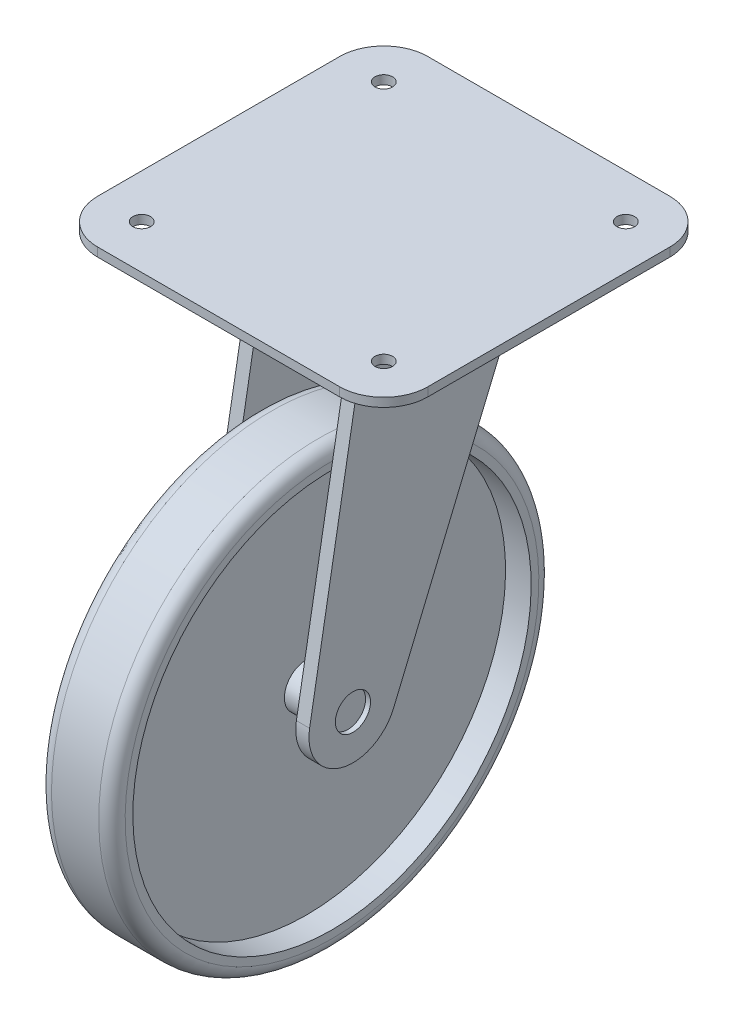
from build123d import *

# Parameters (mm, degrees)
SKETCH1_W           = 75
SKETCH1_H           = 75
SKETCH1_R           = 2
BOSS_EXTRUDE1_DEPTH = 2
FILLET1_R           = 10
SKETCH2_R           = 25
SKETCH2_R_2         = 21.258264894
BOSS_EXTRUDE2_DEPTH = 6
BOSS_EXTRUDE3_START = 10
SKETCH3_R           = 4
BOSS_EXTRUDE3_DEPTH = 3


with BuildPart() as part:
    # Sketch1 → Boss-Extrude1 (new body)
    with BuildSketch(Plane(origin=(0, 0, 0), x_dir=(1, 0, 0), z_dir=(0, 1, 0))):
        Rectangle(SKETCH1_W, SKETCH1_H)
        with Locations((27.5, 27.5)):
            Circle(SKETCH1_R, mode=Mode.SUBTRACT)
        with Locations((27.5, -27.5)):
            Circle(SKETCH1_R, mode=Mode.SUBTRACT)
        with Locations((-27.5, -27.5)):
            Circle(SKETCH1_R, mode=Mode.SUBTRACT)
        with Locations((-27.5, 27.5)):
            Circle(SKETCH1_R, mode=Mode.SUBTRACT)
    extrude(amount=-BOSS_EXTRUDE1_DEPTH)

    # Fillet1
    fillet1_edges = [part.edges().sort_by_distance(p)[0] for p in [
        (-37.5, -1, -37.5),
        (37.5, -1, -37.5),
        (37.5, -1, 37.5),
        (-37.5, -1, 37.5),
    ]]
    fillet(fillet1_edges, radius=FILLET1_R)

    # Sketch2 → Boss-Extrude2 (add)
    with BuildSketch(Plane.XZ.offset(2)):
        Circle(SKETCH2_R)
        Circle(SKETCH2_R_2, mode=Mode.SUBTRACT)
    extrude(amount=BOSS_EXTRUDE2_DEPTH)

    # Sketch3 → Boss-Extrude3 (add)
    with BuildSketch(Plane(origin=(0, 0, 0), x_dir=(0, 0, -1), z_dir=(1, 0, 0)).offset(BOSS_EXTRUDE3_START)):
        with BuildLine():
            Line((-17.549509853, -8), (20.96355147, -8))
            Line((20.96355147, -8), (-10.774863226, -83.859643959))
            ThreePointArc((-10.774863226, -83.859643959), (-22.809331855, -89.597273286), (-29.850246108, -78.275862069))
            Line((-29.850246108, -78.275862069), (-17.549509853, -8))
        make_face()
        with Locations((-20, -80)):
            Circle(SKETCH3_R, mode=Mode.SUBTRACT)
    boss_extrude3 = extrude(amount=BOSS_EXTRUDE3_DEPTH)

    # Mirror1: Boss-Extrude3 across plane
    add(boss_extrude3.mirror(Plane(origin=(0, 0, 0), x_dir=(0, 0, 1), z_dir=(1, 0, 0))))


with BuildPart() as body_2:
    # Sketch4 → Revolve1 (revolve)
    with BuildSketch(Plane.XY.offset(20)):
        with BuildLine():
            Line((2.427228953, -34.748253365), (8.240625297, -34.748253365))
            Line((8.240625297, -34.748253365), (8.240625297, -33))
            ThreePointArc((8.240625297, -33), (7.361945641, -30.878679656), (5.240625297, -30))
            Line((5.240625297, -30), (-5.497712052, -30))
            ThreePointArc((-5.497712052, -30), (-7.619032396, -30.878679656), (-8.497712052, -33))
            Line((-8.497712052, -33), (-8.497712052, -34.748253365))
            Line((-8.497712052, -34.748253365), (-2.649289123, -34.748253365))
            Line((-2.649289123, -34.748253365), (-2.649289123, -75))
            Line((-2.649289123, -75), (-12.118055879, -75))
            Line((-12.118055879, -75), (-12.118055879, -80))
            Line((-12.118055879, -80), (11.871921874, -80))
            Line((11.871921874, -80), (11.871921874, -75))
            Line((11.871921874, -75), (2.427228953, -75))
            Line((2.427228953, -75), (2.427228953, -34.748253365))
        make_face()
    revolve(axis=Axis((-10, -80, 20), (1, 0, 0)))


solid = Compound([part.part, body_2.part])
